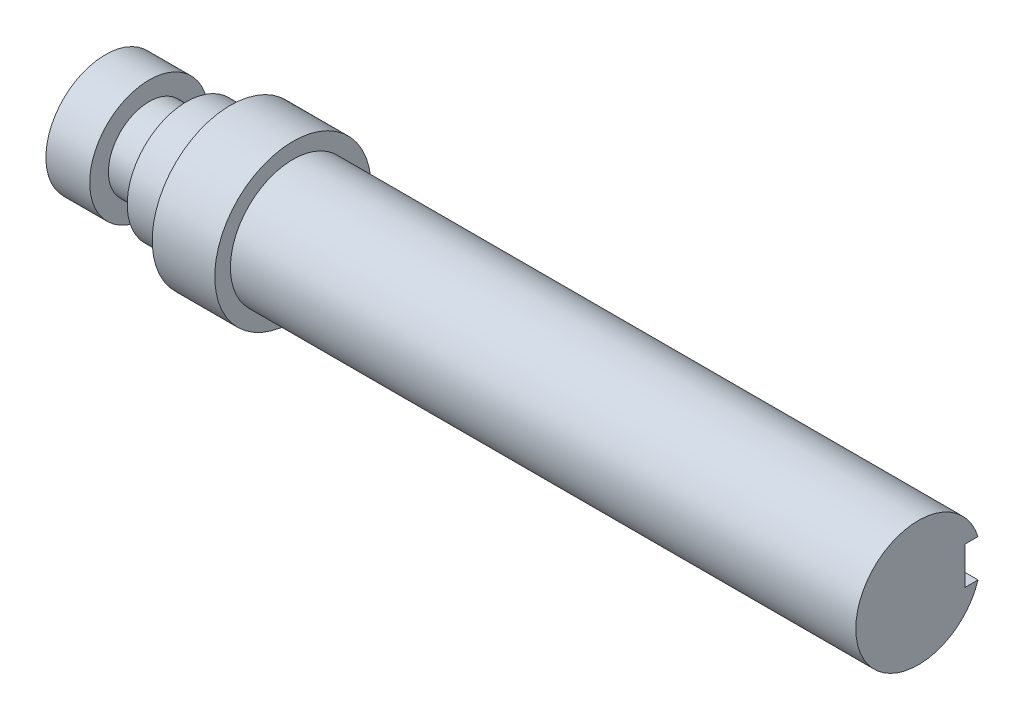
from build123d import *

# Parameters (mm, degrees)
IZIM2_W               = 20
IZIM2_H               = 6
KES_EKSTR_ZYON2_DEPTH = 2.5


with BuildPart() as part:
    # Çizim1 → Döndür1 (revolve)
    with BuildSketch(Plane.XY):
        Polygon((-100, 10), (-100, 12.5), (-110, 12.5), (-110, 9.5), (-117, 9.5), (-117, 6.5), (-123, 6.5), (-123, 9.5), (-130, 9.5), (-130, 0), (0, 0), (0, 10), align=None)
    revolve(axis=Axis((0, 0, 0), (-1, 0, 0)))

    # Çizim2 → Kes-Ekstrüzyon2 (cut)
    with BuildSketch(Plane.XY.offset(-10)):
        with Locations((-10, 0)):
            Rectangle(IZIM2_W, IZIM2_H)
    extrude(amount=KES_EKSTR_ZYON2_DEPTH, mode=Mode.SUBTRACT)


solid = part.part
